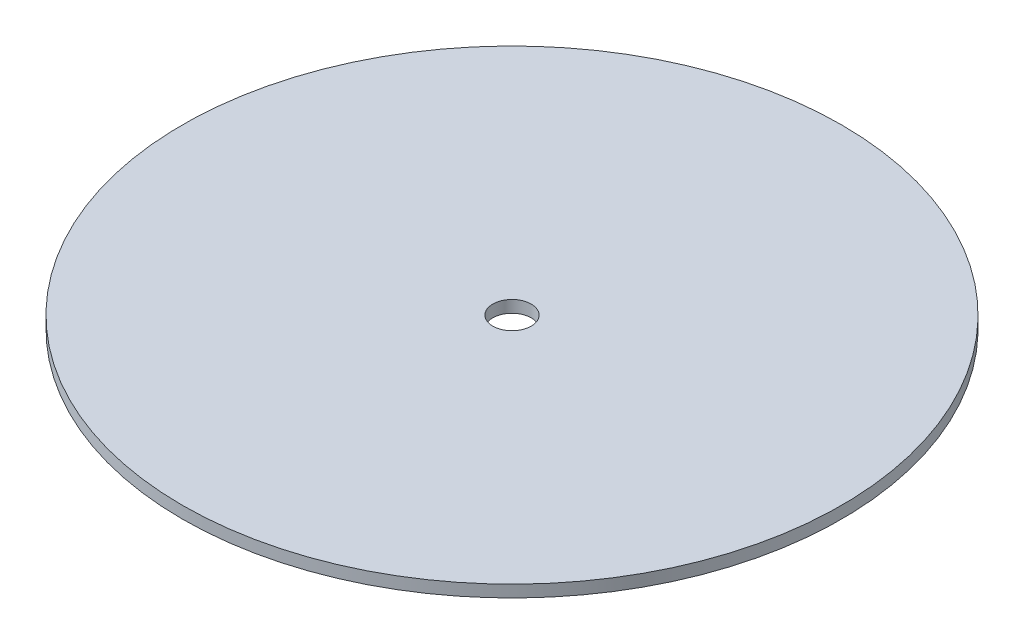
from build123d import *

# Parameters (mm, degrees)
SKETCH1_R           = 137.5
BOSS_EXTRUDE1_DEPTH = 5
SKETCH2_R           = 8
CUT_EXTRUDE1_DEPTH  = 6


with BuildPart() as part:
    # Sketch1 → Boss-Extrude1 (new body)
    with BuildSketch(Plane(origin=(0, 0, 0), x_dir=(1, 0, 0), z_dir=(0, 1, 0))):
        Circle(SKETCH1_R)
    extrude(amount=BOSS_EXTRUDE1_DEPTH)

    # Sketch2 → Cut-Extrude1 (cut, through all)
    with BuildSketch(Plane(origin=(0, 5, 0), x_dir=(1, 0, 0), z_dir=(0, 1, 0))):
        Circle(SKETCH2_R)
    extrude(amount=-CUT_EXTRUDE1_DEPTH, mode=Mode.SUBTRACT)


solid = part.part
